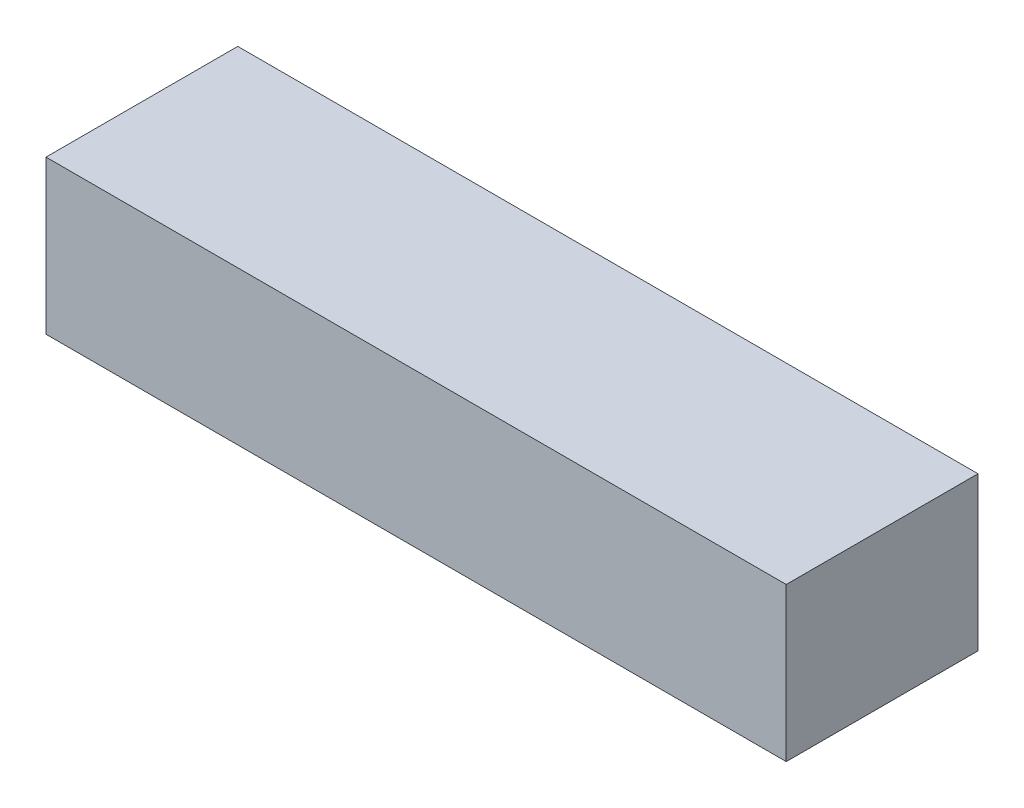
from build123d import *

# Parameters (mm, degrees)
SKETCH1_W           = 77.2
SKETCH1_H           = 20
SKETCH1_W_2         = 16
SKETCH1_H_2         = 16
BOSS_EXTRUDE1_DEPTH = 14
SKETCH2_W           = 77.2
SKETCH2_H           = 20
BOSS_EXTRUDE2_DEPTH = 2


with BuildPart() as part:
    # Sketch1 → Boss-Extrude1 (new body)
    with BuildSketch(Plane(origin=(0, 0, 0), x_dir=(1, 0, 0), z_dir=(0, 1, 0))):
        Rectangle(SKETCH1_W, SKETCH1_H)
        with Locations((-9.6, 0)):
            Rectangle(SKETCH1_W_2, SKETCH1_H_2, mode=Mode.SUBTRACT)
        with Locations((-28.6, 0)):
            Rectangle(SKETCH1_W_2, SKETCH1_H_2, mode=Mode.SUBTRACT)
        with Locations((9.4, 0)):
            Rectangle(SKETCH1_W_2, SKETCH1_H_2, mode=Mode.SUBTRACT)
        with Locations((28.4, 0)):
            Rectangle(SKETCH1_W_2, SKETCH1_H_2, mode=Mode.SUBTRACT)
    extrude(amount=BOSS_EXTRUDE1_DEPTH)

    # Sketch2 → Boss-Extrude2 (add)
    with BuildSketch(Plane(origin=(0, 14, 0), x_dir=(1, 0, 0), z_dir=(0, 1, 0))):
        Rectangle(SKETCH2_W, SKETCH2_H)
    extrude(amount=BOSS_EXTRUDE2_DEPTH)


solid = part.part
